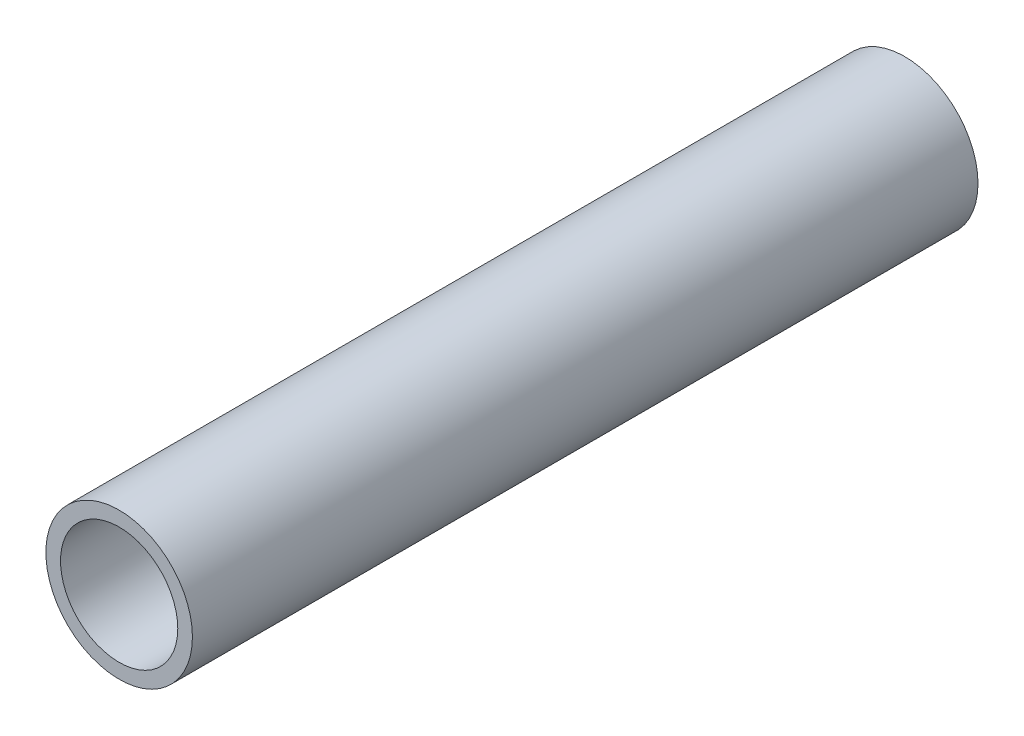
from build123d import *

# Parameters (mm, degrees)
CROQUIS2_R              = 43.75
SALIENTE_EXTRUIR8_DEPTH = 469
CROQUIS4_R              = 35
CORTAR_EXTRUIR1_DEPTH   = 462


with BuildPart() as part:
    # Croquis2 → Saliente-Extruir8 (new body)
    with BuildSketch(Plane.XY):
        Circle(CROQUIS2_R)
    extrude(amount=SALIENTE_EXTRUIR8_DEPTH)

    # Croquis4 → Cortar-Extruir1 (cut)
    with BuildSketch(Plane.XY.offset(469)):
        Circle(CROQUIS4_R)
    extrude(amount=-CORTAR_EXTRUIR1_DEPTH, mode=Mode.SUBTRACT)


solid = part.part
